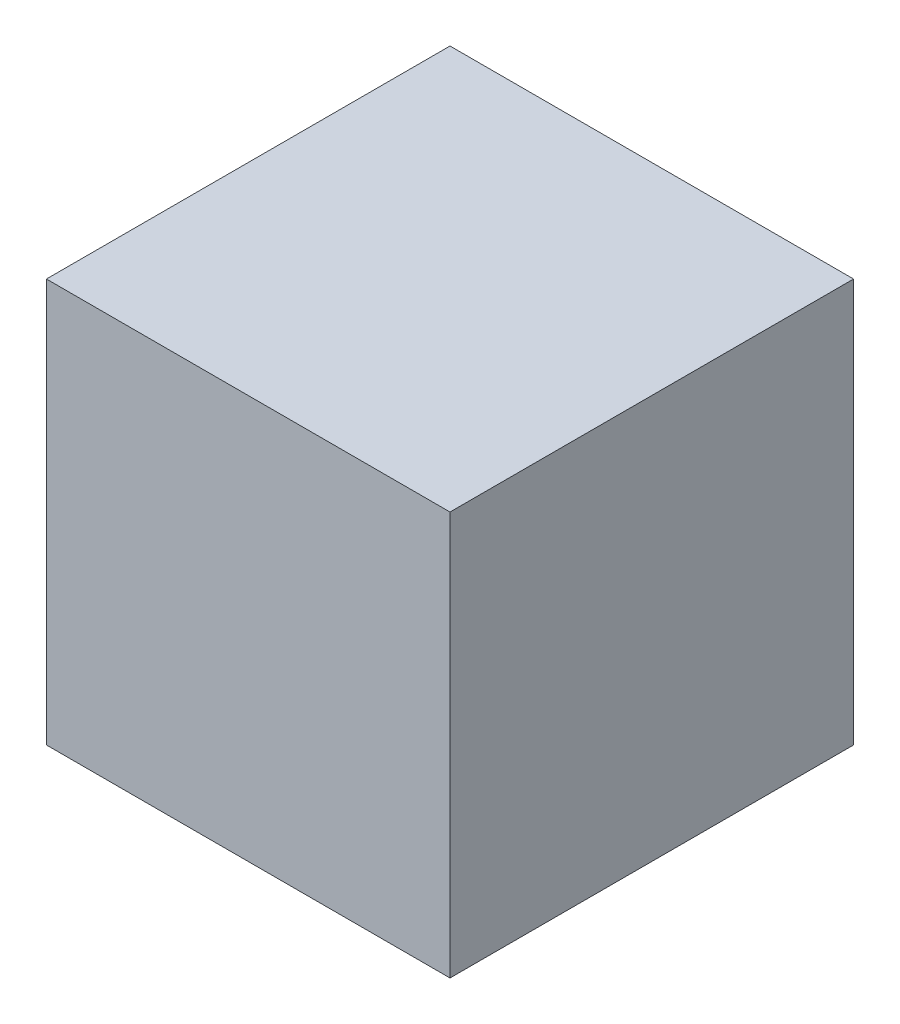
from build123d import *

# Parameters (mm, degrees)
SKETCH1_W           = 400
SKETCH1_H           = 400
BOSS_EXTRUDE1_DEPTH = 400


with BuildPart() as part:
    # Sketch1 → Boss-Extrude1 (new body)
    with BuildSketch(Plane(origin=(0, 0, 0), x_dir=(0, 0, -1), z_dir=(1, 0, 0))):
        with Locations((200, 200)):
            Rectangle(SKETCH1_W, SKETCH1_H)
    extrude(amount=BOSS_EXTRUDE1_DEPTH)


solid = part.part
